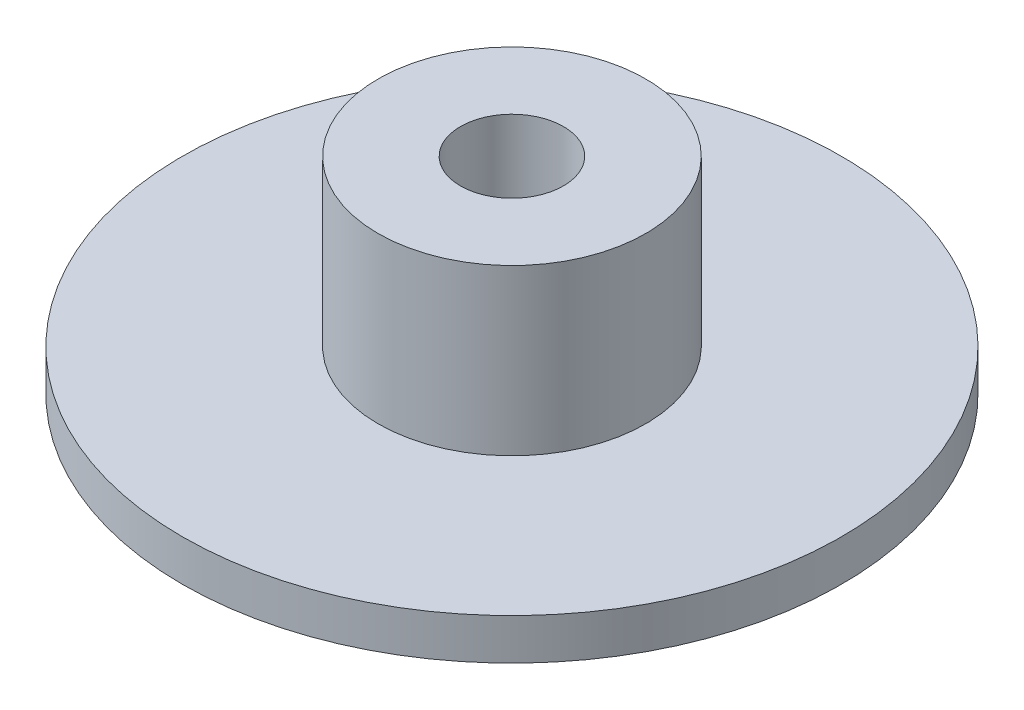
from build123d import *

# Parameters (mm, degrees)
SKETCH_2_R      = 16
SKETCH_2_R_2    = 2.5
EXTRUDE_1_DEPTH = 2
SKETCH_3_R      = 6.5
SKETCH_3_R_2    = 2.5
EXTRUDE_2_DEPTH = 8


with BuildPart() as part:
    # Эскиз2 → Бобышка-Вытянуть1 (new body)
    with BuildSketch(Plane(origin=(0, 0, 0), x_dir=(1, 0, 0), z_dir=(0, 1, 0))):
        Circle(SKETCH_2_R)
        Circle(SKETCH_2_R_2, mode=Mode.SUBTRACT)
    extrude(amount=EXTRUDE_1_DEPTH)

    # Эскиз3 → Бобышка-Вытянуть2 (add)
    with BuildSketch(Plane(origin=(0, 2, 0), x_dir=(1, 0, 0), z_dir=(0, 1, 0))):
        Circle(SKETCH_3_R)
        Circle(SKETCH_3_R_2, mode=Mode.SUBTRACT)
    extrude(amount=EXTRUDE_2_DEPTH)


solid = part.part
